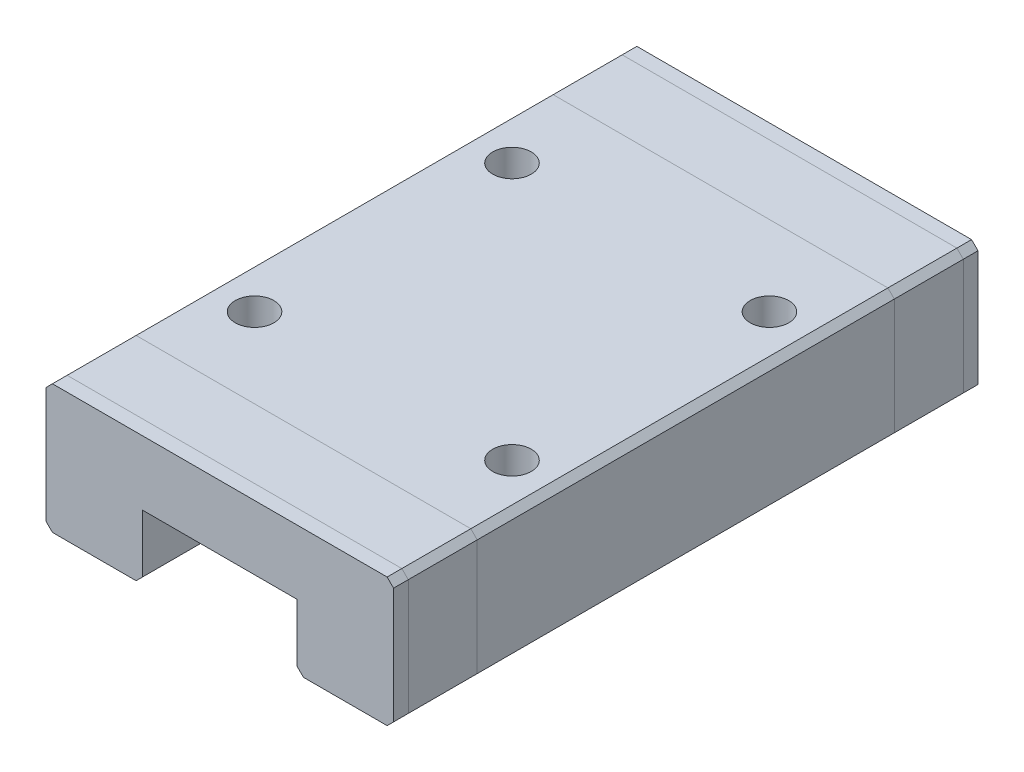
from build123d import *

# Parameters (mm, degrees)
EXTRUDE_1_DEPTH     = 45.4
SKETCH_2_R          = 1.5
CUT_EXTRUDE_1_DEPTH = 2.5
CHAMFER_1_SIZE      = 0.5


with BuildPart() as part:
    # 草图1 → 凸台-拉伸1 (new body)
    with BuildSketch(Plane.XY):
        Polygon((0, 0), (7.5, 0), (7.5, 5), (19.5, 5), (19.5, 0), (27, 0), (27, 10), (0, 10), align=None)
    extrude(amount=EXTRUDE_1_DEPTH)

    # 草图2 → 切除-拉伸1 (cut)
    with BuildSketch(Plane(origin=(0, 10, 0), x_dir=(1, 0, 0), z_dir=(0, 1, 0))):
        with Locations((23.5, -12.7)):
            Circle(SKETCH_2_R)
        with Locations((3.5, -12.7)):
            Circle(SKETCH_2_R)
        with Locations((23.5, -32.7)):
            Circle(SKETCH_2_R)
        with Locations((3.5, -32.7)):
            Circle(SKETCH_2_R)
    extrude(amount=-CUT_EXTRUDE_1_DEPTH, mode=Mode.SUBTRACT)

    # 倒角1
    chamfer_1_edges = [part.edges().sort_by_distance(p)[0] for p in [
        (0, 10, 22.7),
        (27, 10, 22.7),
        (27, 0, 22.7),
        (19.5, 0, 22.7),
        (7.5, 0, 22.7),
        (0, 0, 22.7),
    ]]
    chamfer(chamfer_1_edges, length=CHAMFER_1_SIZE)


solid = part.part
